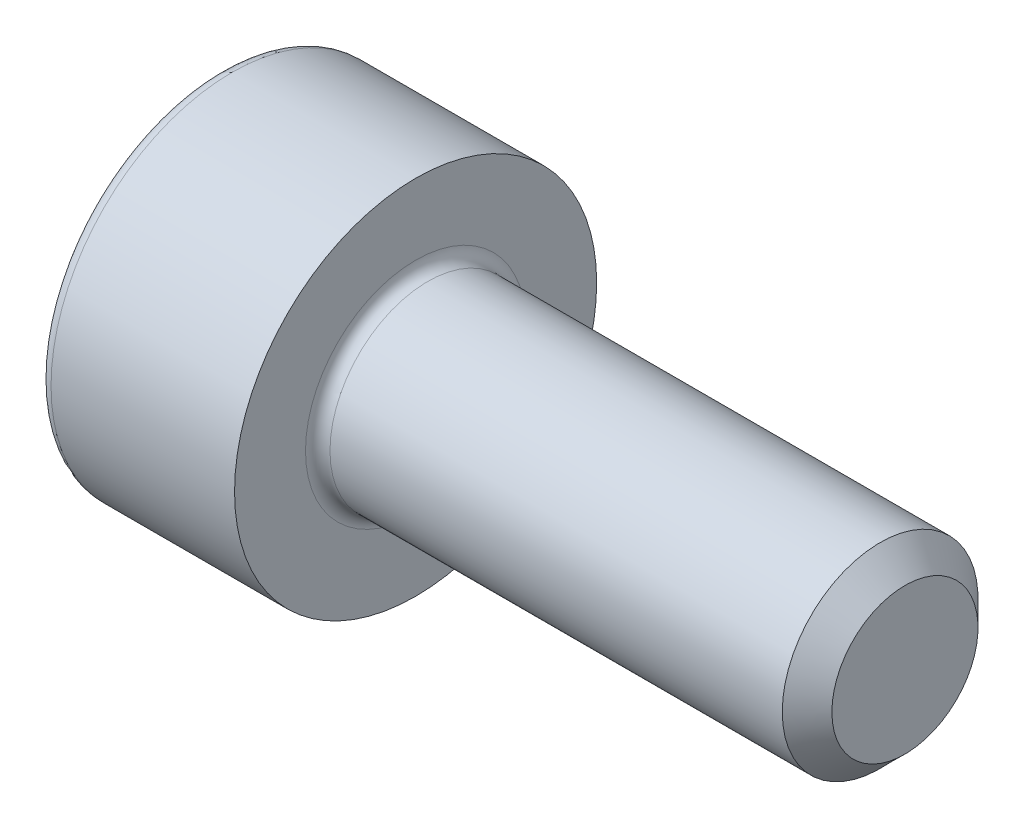
from build123d import *

# Parameters (mm, degrees)
CUT_EXTRUDE1_DEPTH = 1.1


with BuildPart() as part:
    # Sketch1 → Revolve1 (revolve)
    with BuildSketch(Plane.XY):
        with BuildLine():
            Line((4.7465, 1), (0.125, 1))
            ThreePointArc((0.125, 1), (0.036611652, 1.036611652), (0, 1.125))
            Line((0, 1.125), (0, 1.85))
            Line((0, 1.85), (-1.875, 1.85))
            ThreePointArc((-1.875, 1.85), (-1.963388348, 1.813388348), (-2, 1.725))
            Line((-2, 1.725), (-2, 0))
            Line((-2, 0), (5, 0))
            Line((5, 0), (5, 0.7465))
            Line((5, 0.7465), (4.7465, 1))
        make_face()
    revolve(axis=Axis((-2, 0, 0), (1, 0, 0)))

    # Sketch2 → Cut-Extrude1 (cut)
    with BuildSketch(Plane.ZY.offset(2)):
        Polygon((0.75, 0.433012702), (0, 0.866025404), (-0.75, 0.433012702), (-0.75, -0.433012702), (0, -0.866025404), (0.75, -0.433012702), align=None)
    extrude(amount=-CUT_EXTRUDE1_DEPTH, mode=Mode.SUBTRACT)


solid = part.part
